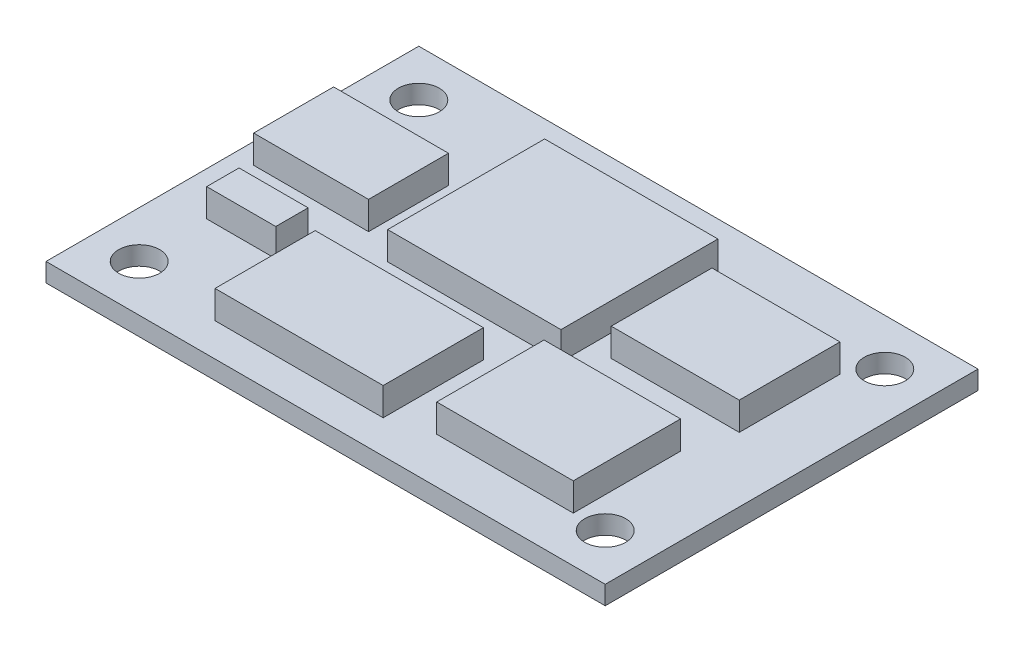
from build123d import *

# Parameters (mm, degrees)
SKETCH1_W                  = 60
SKETCH1_H                  = 40
BOSS_EXTRUDE1_DEPTH        = 2
SKETCH2_W                  = 12.326283063
SKETCH2_H                  = 8.575111395
SKETCH2_W_2                = 13.737384573
SKETCH2_H_2                = 10.808942535
SKETCH2_W_3                = 18.592828035
SKETCH2_H_3                = 16.842728436
SKETCH2_W_4                = 7.411585369
SKETCH2_H_4                = 3.471203566
SKETCH2_W_5                = 14.654892662
SKETCH2_H_5                = 11.51389599
SKETCH2_W_6                = 18.043574534
SKETCH2_H_6                = 10.748392007
BOSS_EXTRUDE2_DEPTH        = 3
F_4_4_4_4_DIAMETER_HOLE1_D = 4.4


with BuildPart() as part:
    # Sketch1 → Boss-Extrude1 (new body)
    with BuildSketch(Plane(origin=(0, 0, 0), x_dir=(1, 0, 0), z_dir=(0, 1, 0))):
        Rectangle(SKETCH1_W, SKETCH1_H)
    extrude(amount=BOSS_EXTRUDE1_DEPTH)

    # Sketch2 → Boss-Extrude2 (add)
    with BuildSketch(Plane(origin=(0, 2, 0), x_dir=(1, 0, 0), z_dir=(0, 1, 0))):
        with Locations((-21.625666124, 4.358295229)):
            Rectangle(SKETCH2_W, SKETCH2_H)
        with Locations((16.207165307, 6.711999232)):
            Rectangle(SKETCH2_W_2, SKETCH2_H_2)
        with Locations((-2.33436777, 6.711999232)):
            Rectangle(SKETCH2_W_3, SKETCH2_H_3)
        with Locations((-21.625666124, -5.692081798)):
            Rectangle(SKETCH2_W_4, SKETCH2_H_4)
        with Locations((14.346591679, -9.340896656)):
            Rectangle(SKETCH2_W_5, SKETCH2_H_5)
        with Locations((-6.403086195, -11.066277802)):
            Rectangle(SKETCH2_W_6, SKETCH2_H_6)
    extrude(amount=BOSS_EXTRUDE2_DEPTH)

    # Ø4.4 (4.4) Diameter Hole1 (through all)
    with Locations(Plane(origin=(0, 2, 0), x_dir=(1, 0, 0), z_dir=(0, 1, 0))):
        with Locations((-25, 15), (25, 15), (25, -15), (-25, -15)):
            Hole(F_4_4_4_4_DIAMETER_HOLE1_D / 2)


solid = part.part
